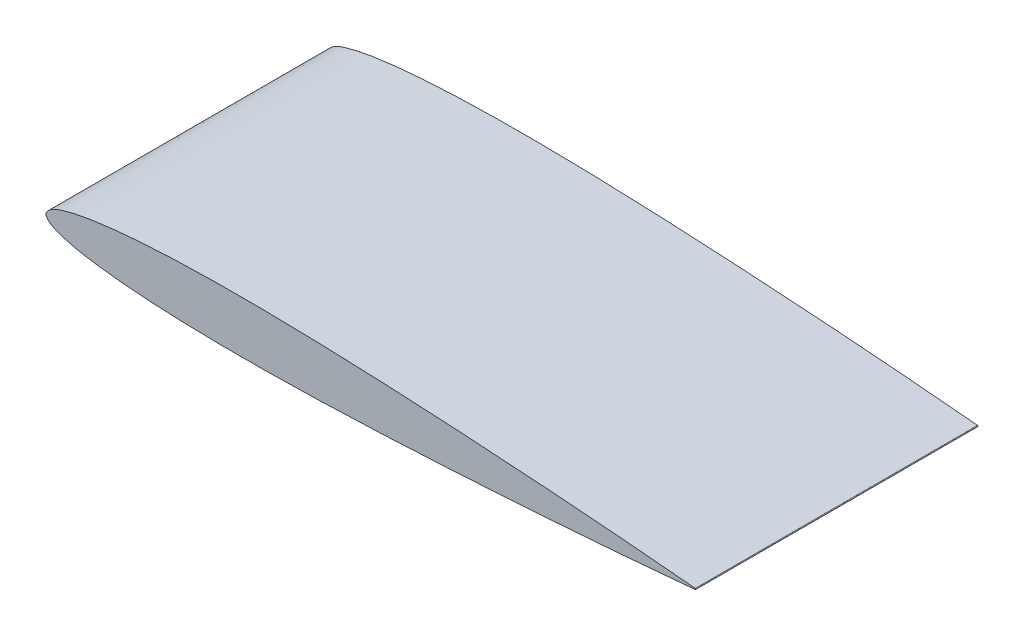
from build123d import *

# Parameters (mm, degrees)
BOSS_EXTRUDE1_DEPTH = 50


with BuildPart() as part:
    # Sketch4 → Boss-Extrude1 (new body)
    with BuildSketch(Plane.XY):
        with BuildLine():
            ThreePointArc((115, 0.0966), (115.088150903, 0), (115, -0.0966))
            add(Edge.make_bspline(
                [(115, 0.0966), (113.083512137, 0.272258452), (109.251373934, 0.623498592), (101.585893564, 1.277533827), (92.00378736, 2.028152644), (80.503448773, 2.826540946), (69.003570319, 3.521009882), (57.503459891, 4.084960093), (46.002988341, 4.488388468), (36.417005709, 4.629049173), (28.74902779, 4.57347386), (22.997441925, 4.421722858), (17.242367601, 4.131360002), (12.451261675, 3.723299316), (8.612412546, 3.236124572), (5.742633848, 2.764224018), (3.277070291, 2.148114318), (1.340225528, 1.51913534), (-0.764305852, 0), (1.340225528, -1.51913534), (3.277070291, -2.148114318), (5.742633848, -2.764224018), (8.612412546, -3.236124572), (12.451261675, -3.723299316), (17.242367601, -4.131360002), (22.997441925, -4.421722858), (28.74902779, -4.57347386), (36.417005709, -4.629049173), (46.002988341, -4.488388468), (57.503459891, -4.084960093), (69.003570319, -3.521009882), (80.503448773, -2.826540946), (92.00378736, -2.028152644), (101.585893564, -1.277533827), (109.251373934, -0.623498592), (113.083512137, -0.272258452), (115, -0.0966)],
                knots=[0, 0, 0, 0, 0.024876293, 0.049741715, 0.099443402, 0.149112224, 0.198750974, 0.248359097, 0.29793737, 0.347491327, 0.37226694, 0.397050924, 0.421859475, 0.446731346, 0.459220451, 0.471790602, 0.484560454, 0.491195112, 0.5, 0.508804888, 0.515439546, 0.528209398, 0.540779549, 0.553268654, 0.578140525, 0.602949076, 0.62773306, 0.652508673, 0.70206263, 0.751640903, 0.801249026, 0.850887776, 0.900556598, 0.950258285, 0.975123707, 1, 1, 1, 1], degree=3))
        make_face()
    extrude(amount=BOSS_EXTRUDE1_DEPTH)


solid = part.part
